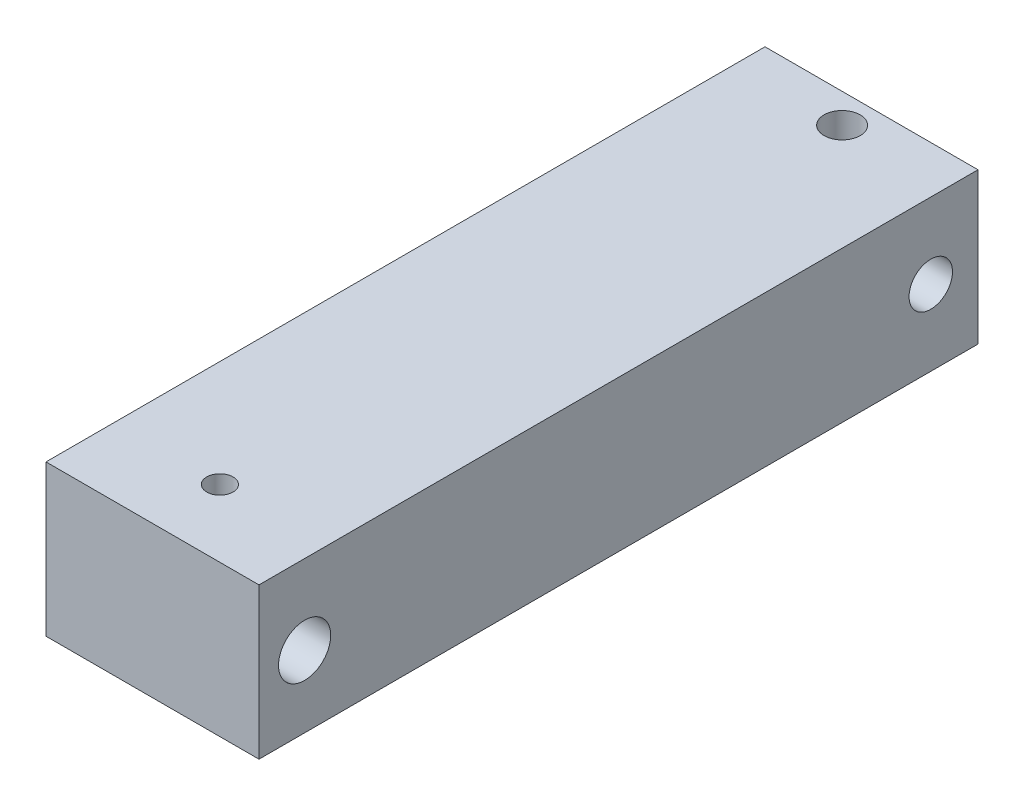
from build123d import *

# Parameters (mm, degrees)
SKETCH_1_W          = 34.660183122
SKETCH_1_H          = 24.57042631
EXTRUDE_1_DEPTH     = 117
SKETCH_2_R          = 2.936506095
SKETCH_2_R_2        = 2.138363717
CUT_EXTRUDE_1_DEPTH = 117
SKETCH_3_R          = 4.242126228
CUT_EXTRUDE_2_DEPTH = 117
SKETCH_4_R          = 3.532728848
CUT_EXTRUDE_3_DEPTH = 50


with BuildPart() as part:
    # 草图1 → 凸台-拉伸1 (new body)
    with BuildSketch(Plane.XY):
        with Locations((17.330091561, 12.285213155)):
            Rectangle(SKETCH_1_W, SKETCH_1_H)
    extrude(amount=EXTRUDE_1_DEPTH)

    # 草图2 → 切除-拉伸1 (cut)
    with BuildSketch(Plane(origin=(0, 24.57042631, 0), x_dir=(1, 0, 0), z_dir=(0, 1, 0))):
        with Locations((17.330091561, -4.778141965)):
            Circle(SKETCH_2_R)
        with Locations((17.330091561, -106.034000041)):
            Circle(SKETCH_2_R_2)
    extrude(amount=-CUT_EXTRUDE_1_DEPTH, mode=Mode.SUBTRACT)

    # 草图3 → 切除-拉伸2 (cut)
    with BuildSketch(Plane.ZY):
        with Locations((109.575398108, 11.633186796)):
            Circle(SKETCH_3_R)
    extrude(amount=-CUT_EXTRUDE_2_DEPTH, mode=Mode.SUBTRACT)

    # 草图4 → 切除-拉伸3 (cut)
    with BuildSketch(Plane(origin=(34.660183122, 0, 0), x_dir=(0, 0, -1), z_dir=(1, 0, 0))):
        with Locations((-7.685412436, 12.285213155)):
            Circle(SKETCH_4_R)
    extrude(amount=-CUT_EXTRUDE_3_DEPTH, mode=Mode.SUBTRACT)


solid = part.part
